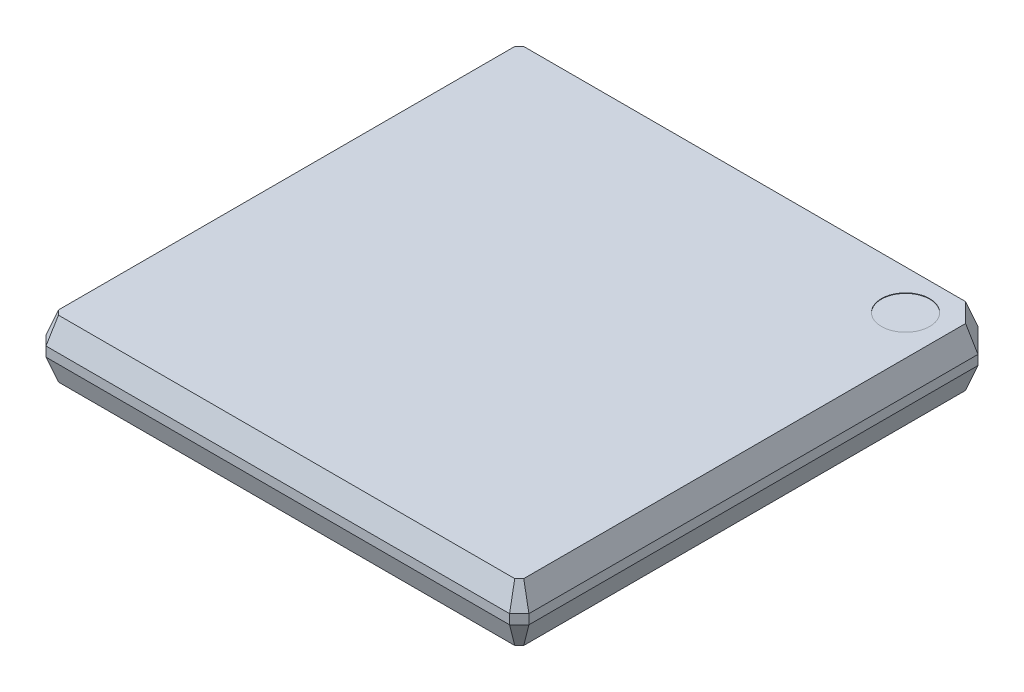
from build123d import *

# Parameters (mm, degrees)
SKETCH1_W           = 10
SKETCH1_H           = 10
BOSS_EXTRUDE1_DEPTH = 0.1
CHAMFER1_SIZE       = 0.2
CHAMFER2_SIZE       = 0.5
BOSS_EXTRUDE2_DEPTH = 0.5
BOSS_EXTRUDE2_TAPER = 20
SKETCH3_R           = 0.5
CUT_EXTRUDE1_DEPTH  = 0.01


with BuildPart() as part:
    # Sketch1 → Boss-Extrude1 (new body, symmetric)
    with BuildSketch(Plane(origin=(0, 0, 0), x_dir=(1, 0, 0), z_dir=(0, 1, 0))):
        Rectangle(SKETCH1_W, SKETCH1_H)
    extrude(amount=BOSS_EXTRUDE1_DEPTH, both=True)

    # Chamfer1
    chamfer1_edges = [part.edges().sort_by_distance(p)[0] for p in [
        (5, 0, 5),
        (-5, 0, 5),
        (-5, 0, -5),
    ]]
    chamfer(chamfer1_edges, length=CHAMFER1_SIZE)

    # Chamfer2
    chamfer2_edges = [part.edges().sort_by_distance(p)[0] for p in [
        (5, 0, -5),
    ]]
    chamfer(chamfer2_edges, length=CHAMFER2_SIZE)

    # Sketch2 → Boss-Extrude2 (add)
    with BuildSketch(Plane(origin=(0, 0.1, 0), x_dir=(1, 0, 0), z_dir=(0, 1, 0))):
        Polygon((-4.8, 5), (-5, 4.8), (-5, -4.8), (-4.8, -5), (4.8, -5), (5, -4.8), (5, 4.5), (4.5, 5), align=None)
    boss_extrude2 = extrude(amount=BOSS_EXTRUDE2_DEPTH, taper=BOSS_EXTRUDE2_TAPER)

    # Mirror1: Boss-Extrude2 across plane
    add(boss_extrude2.mirror(Plane.ZX))

    # Sketch3 → Cut-Extrude1 (cut)
    with BuildSketch(Plane(origin=(0, 0.6, 0), x_dir=(1, 0, 0), z_dir=(0, 1, 0))):
        with Locations((4, 4)):
            Circle(SKETCH3_R)
    extrude(amount=-CUT_EXTRUDE1_DEPTH, mode=Mode.SUBTRACT)


solid = part.part
